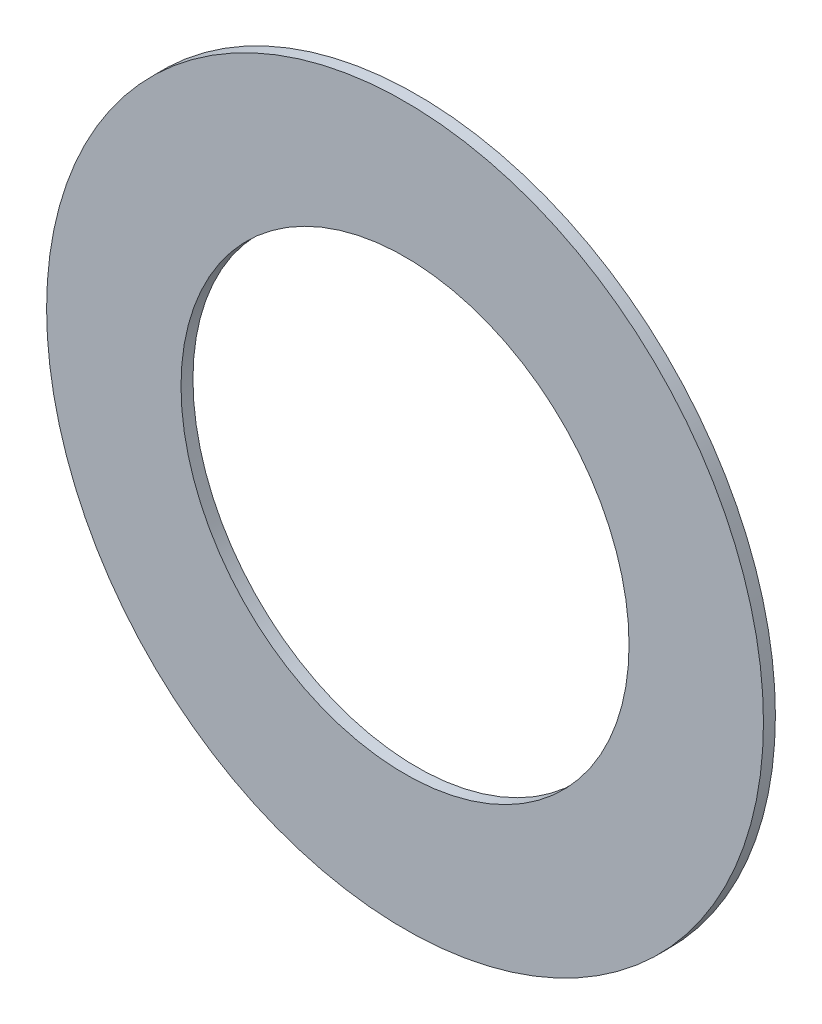
from build123d import *

# Parameters (mm, degrees)
SKETCH1_R           = 15.24
BOSS_EXTRUDE1_DEPTH = 0.508
SKETCH2_R           = 9.525
CUT_EXTRUDE1_DEPTH  = 1.508


with BuildPart() as part:
    # Sketch1 → Boss-Extrude1 (new body)
    with BuildSketch(Plane.XY):
        Circle(SKETCH1_R)
    extrude(amount=BOSS_EXTRUDE1_DEPTH)

    # Sketch2 → Cut-Extrude1 (cut, through all)
    with BuildSketch(Plane.XY.offset(0.508)):
        Circle(SKETCH2_R)
    extrude(amount=-CUT_EXTRUDE1_DEPTH, mode=Mode.SUBTRACT)


solid = part.part
